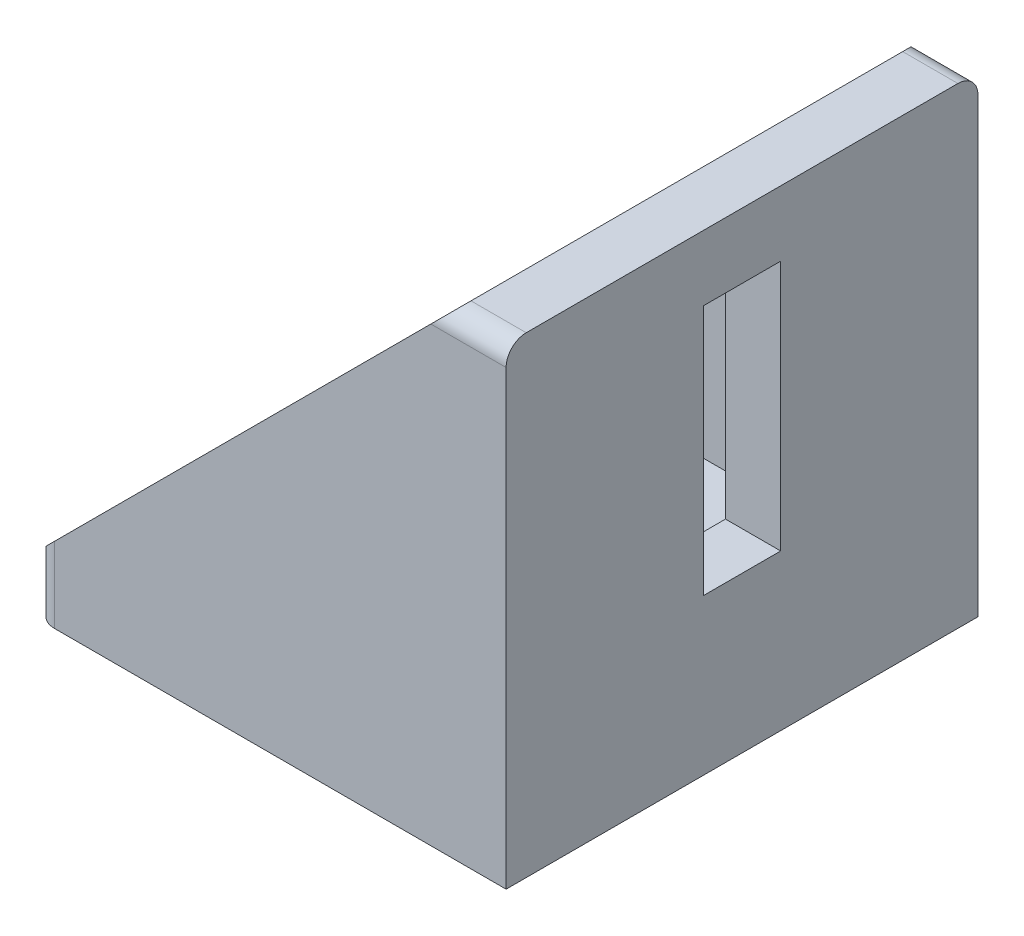
from build123d import *

# Parameters (mm, degrees)
BOSS_EXTRUDE1_DEPTH = 23.5
CUT_EXTRUDE1_DEPTH  = 18
SKETCH3_W           = 7.7
SKETCH3_H           = 25
CUT_EXTRUDE2_DEPTH  = 6.5
SKETCH4_W           = 25
SKETCH4_H           = 7.7
CUT_EXTRUDE3_DEPTH  = 6.5
FILLET1_R           = 2


with BuildPart() as part:
    # Sketch1 → Boss-Extrude1 (new body, symmetric)
    with BuildSketch(Plane.XY):
        Polygon((-47, 0), (0, 0), (0, 47), (-5.5, 47), (-47, 5.5), align=None)
    extrude(amount=BOSS_EXTRUDE1_DEPTH, both=True)

    # Sketch2 → Cut-Extrude1 (cut, symmetric)
    with BuildSketch(Plane.XY):
        Polygon((-5.5, 47), (-5.5, 5.5), (-47, 5.5), align=None)
    extrude(amount=CUT_EXTRUDE1_DEPTH, both=True, mode=Mode.SUBTRACT)

    # Sketch3 → Cut-Extrude2 (cut, through all)
    with BuildSketch(Plane.ZY.offset(5.5)):
        with Locations((0, 28)):
            Rectangle(SKETCH3_W, SKETCH3_H)
    extrude(amount=-CUT_EXTRUDE2_DEPTH, mode=Mode.SUBTRACT)

    # Sketch4 → Cut-Extrude3 (cut, through all)
    with BuildSketch(Plane(origin=(0, 5.5, 0), x_dir=(1, 0, 0), z_dir=(0, 1, 0))):
        with Locations((-25, 0)):
            Rectangle(SKETCH4_W, SKETCH4_H)
    extrude(amount=-CUT_EXTRUDE3_DEPTH, mode=Mode.SUBTRACT)

    # Fillet1
    fillet1_edges = [part.edges().sort_by_distance(p)[0] for p in [
        (-2.75, 47, 23.5),
        (-47, 2.75, 23.5),
        (-2.75, 47, -23.5),
        (-47, 2.75, -23.5),
    ]]
    fillet(fillet1_edges, radius=FILLET1_R)


solid = part.part
